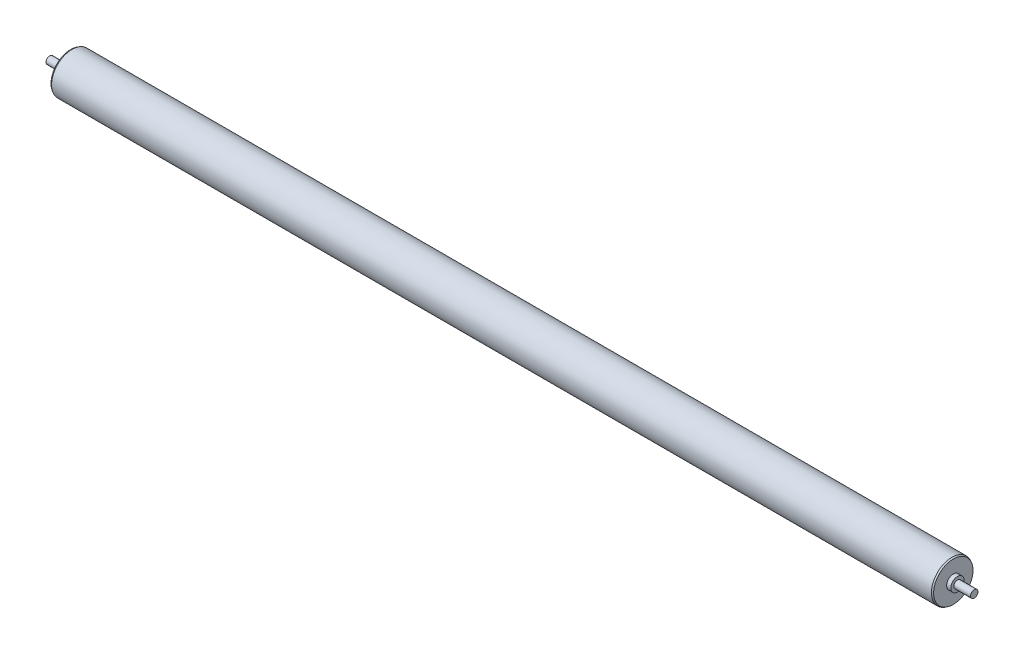
from build123d import *

# Parameters (mm, degrees)
REVOLVE1_ANGLE = 360


with BuildPart() as part:
    # Sketch2 → Revolve1 (revolve, symmetric)
    with BuildSketch(Plane.XY) as revolve1_sk:
        Polygon((-393.7, 0), (-393.7, 3.175), (-379.4125, 3.175), (-379.4125, 5.715), (-375.840625, 5.715), (-375.840625, 16.775092336), (-374.65, 17.4625), (374.65, 17.4625), (375.840625, 16.775092336), (375.840625, 5.715), (379.4125, 5.715), (379.4125, 3.175), (393.7, 3.175), (393.7, 0), align=None)
    revolve(axis=Axis((-393.7, 0, 0), (1, 0, 0)), revolution_arc=REVOLVE1_ANGLE / 2)
    revolve(revolve1_sk.sketch, axis=Axis((-393.7, 0, 0), (-1, 0, 0)), revolution_arc=REVOLVE1_ANGLE / 2)


solid = part.part
